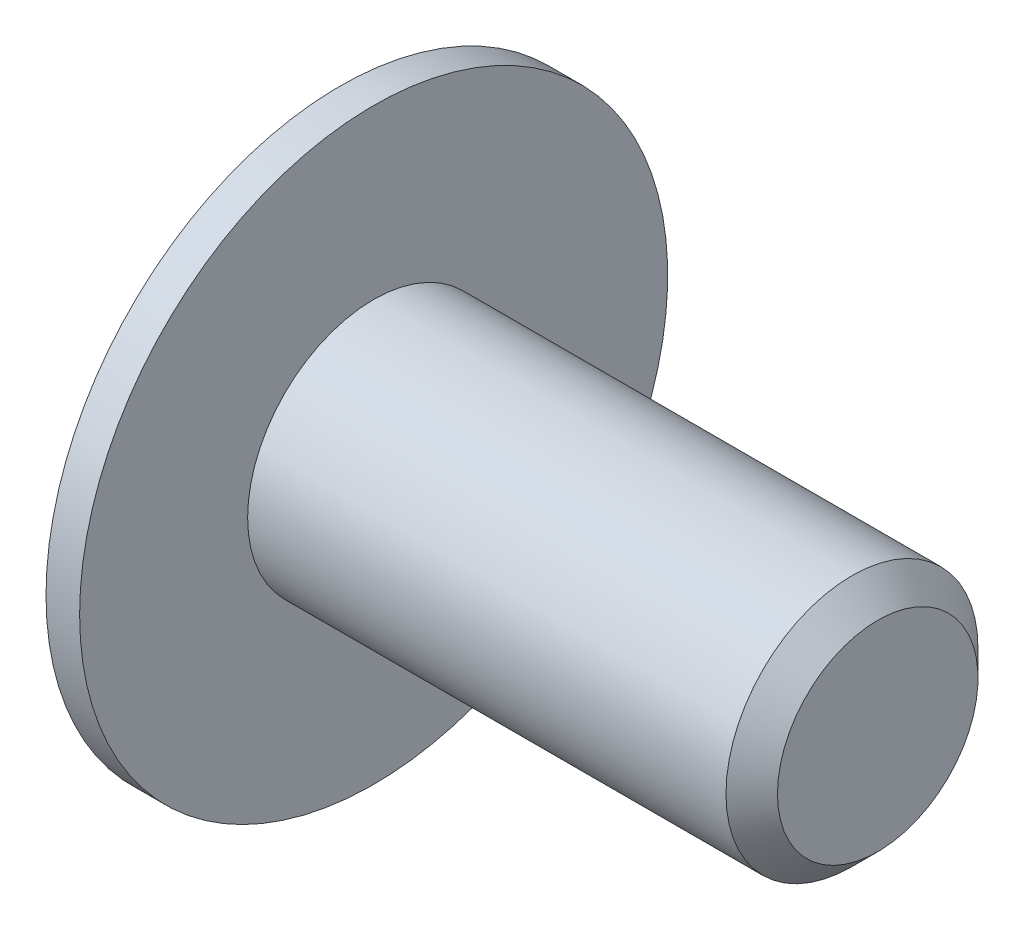
from build123d import *

# Parameters (mm, degrees)
CUT_EXTRUDE1_DEPTH = 0.4


with BuildPart() as part:
    # Sketch1 → Revolve1 (revolve)
    with BuildSketch(Plane.XY):
        Polygon((-0.8, 0), (-0.8, 2.8), (-0.4, 3.5), (0, 3.5), (0, 1.5), (5.6935, 1.5), (6, 1.1935), (6, 0), align=None)
    revolve(axis=Axis((6, 0, 0), (-1, 0, 0)))

    # Sketch2 → Cut-Extrude1 (cut)
    with BuildSketch(Plane(origin=(-0.8, 0, 0), x_dir=(0, 0, -1), z_dir=(1, 0, 0))):
        with BuildLine():
            Line((-1.166666667, 0.233333357), (-1.166666667, -0.233333333))
            Line((-1.166666667, -0.233333333), (-0.46666669, -0.233333333))
            ThreePointArc((-0.46666669, -0.233333333), (-0.301675108, -0.301675084), (-0.233333357, -0.466666667))
            Line((-0.233333357, -0.466666667), (-0.233333357, -1.166666667))
            Line((-0.233333357, -1.166666667), (0.233333333, -1.166666667))
            Line((0.233333333, -1.166666667), (0.233333333, -0.466666667))
            ThreePointArc((0.233333333, -0.466666667), (0.301675084, -0.301675084), (0.466666667, -0.233333333))
            Line((0.466666667, -0.233333333), (1.166666667, -0.233333333))
            Line((1.166666667, -0.233333333), (1.166666667, 0.233333357))
            Line((1.166666667, 0.233333357), (0.466666667, 0.233333357))
            ThreePointArc((0.466666667, 0.233333357), (0.301675084, 0.301675108), (0.233333333, 0.46666669))
            Line((0.233333333, 0.46666669), (0.233333333, 1.166666667))
            Line((0.233333333, 1.166666667), (-0.233333357, 1.166666667))
            Line((-0.233333357, 1.166666667), (-0.233333357, 0.46666669))
            ThreePointArc((-0.233333357, 0.46666669), (-0.301675108, 0.301675108), (-0.46666669, 0.233333357))
            Line((-0.46666669, 0.233333357), (-1.166666667, 0.233333357))
        make_face()
    extrude(amount=CUT_EXTRUDE1_DEPTH, mode=Mode.SUBTRACT)


solid = part.part
